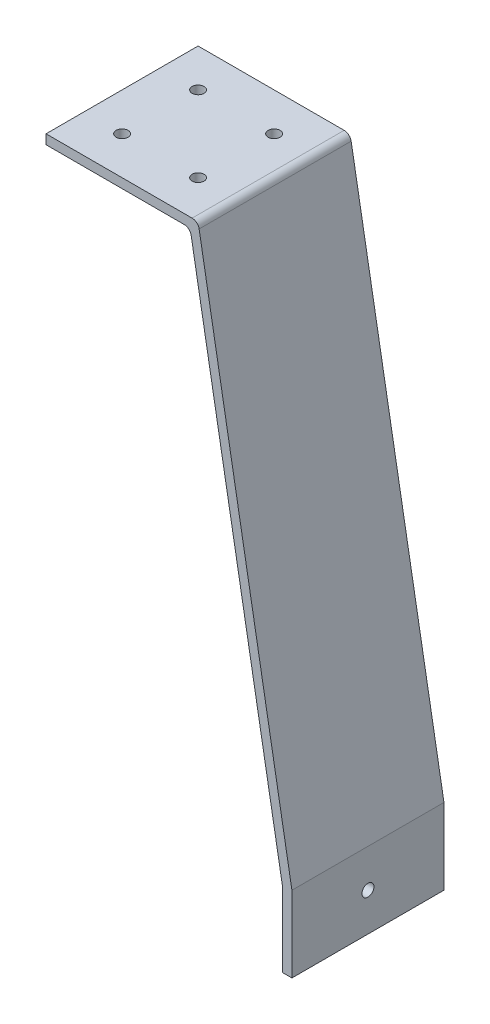
from build123d import *

# Parameters (mm, degrees)
BOSS_EXTRUDE1_DEPTH = 25.4
SKETCH3_R           = 2
CUT_EXTRUDE1_DEPTH  = 50.8
SKETCH4_R           = 2
CUT_EXTRUDE2_DEPTH  = 83.15093717
FILLET1_R           = 2.38


with BuildPart() as part:
    # Sketch1 → Boss-Extrude1 (new body, symmetric)
    with BuildSketch(Plane.XY):
        Polygon((0, 0), (50.8, 0), (82.15093717, -177.8), (82.15093717, -203.2), (78.97593717, -203.2), (78.97593717, -178.077776507), (48.135858671, -3.175), (0, -3.175), align=None)
    extrude(amount=BOSS_EXTRUDE1_DEPTH, both=True)

    # Sketch3 → Cut-Extrude1 (cut)
    with BuildSketch(Plane(origin=(0, 0, 0), x_dir=(1, 0, 0), z_dir=(0, 1, 0))):
        with Locations((12.7, -12.7)):
            Circle(SKETCH3_R)
        with Locations((12.7, 12.7)):
            Circle(SKETCH3_R)
        with Locations((38.1, 12.7)):
            Circle(SKETCH3_R)
        with Locations((38.1, -12.7)):
            Circle(SKETCH3_R)
    extrude(amount=-CUT_EXTRUDE1_DEPTH, mode=Mode.SUBTRACT)

    # Sketch4 → Cut-Extrude2 (cut, through all)
    with BuildSketch(Plane(origin=(82.15093717, 0, 0), x_dir=(0, 0, -1), z_dir=(1, 0, 0))):
        with Locations((0, -190.5)):
            Circle(SKETCH4_R)
    extrude(amount=-CUT_EXTRUDE2_DEPTH, mode=Mode.SUBTRACT)

    # Fillet1
    fillet1_edges = [part.edges().sort_by_distance(p)[0] for p in [
        (50.8, 0, 0),
        (48.135858671, -3.175, 0),
    ]]
    fillet(fillet1_edges, radius=FILLET1_R)


solid = part.part
